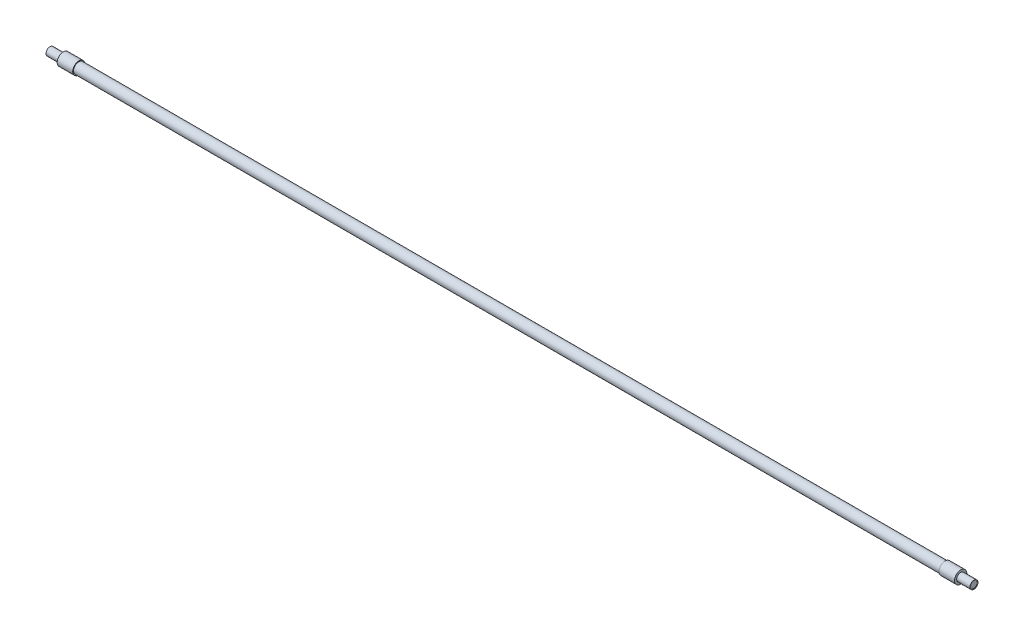
from build123d import *

# Parameters (mm, degrees)
FILLET1_R           = 0.4
SKETCH6_R           = 5.25
BOSS_EXTRUDE1_DEPTH = 853.2
SKETCH7_R           = 3.175
CUT_EXTRUDE1_DEPTH  = 0.2
SKETCH9_R           = 3.175
CUT_EXTRUDE2_DEPTH  = 0.2


with BuildPart() as part:
    # Sketch3 → Revolve1 (revolve)
    with BuildSketch(Plane.XY, mode=Mode.PRIVATE) as revolve1_sk:
        Polygon((0, 0), (0, 3.95), (13.1, 3.95), (13.1, 6.05), (28.4, 6.05), (28.4, 0), align=None)
    revolve1 = revolve(revolve1_sk.sketch.rotate(Axis((0, 0, 0), (1, 0, 0)), 90), axis=Axis((0, 0, 0), (1, 0, 0)))  # turned: the seam where the file's is

    # Fillet1
    fillet1_edges = [part.edges().sort_by_distance(p)[0] for p in [
        (13.1, 0, -3.95),
    ]]
    fillet(fillet1_edges, radius=FILLET1_R)

    # Sketch6 → Boss-Extrude1 (add)
    with BuildSketch(Plane(origin=(28.4, 0, 0), x_dir=(0, 0, -1), z_dir=(1, 0, 0))):
        with Locations(Location((0, 0, 0), (0, 0, 180))):  # turned: the seam where the file's is
            Circle(SKETCH6_R)
    extrude(amount=BOSS_EXTRUDE1_DEPTH)

    # Mirror1: Revolve1 across plane
    add(revolve1.mirror(Plane(origin=(455, 0, 0), x_dir=(0, 0, 1), z_dir=(1, 0, 0))))

    # Sketch7 → Cut-Extrude1 (cut)
    with BuildSketch(Plane(origin=(910, 0, 0), x_dir=(0, 0, -1), z_dir=(1, 0, 0))):
        Circle(SKETCH7_R)
    extrude(amount=-CUT_EXTRUDE1_DEPTH, mode=Mode.SUBTRACT)

    # Sketch9 → Cut-Extrude2 (cut)
    with BuildSketch(Plane.ZY):
        with Locations(Location((0, 0, 0), (0, 0, 180))):  # turned: the seam where the file's is
            Circle(SKETCH9_R)
    extrude(amount=-CUT_EXTRUDE2_DEPTH, mode=Mode.SUBTRACT)


solid = part.part
